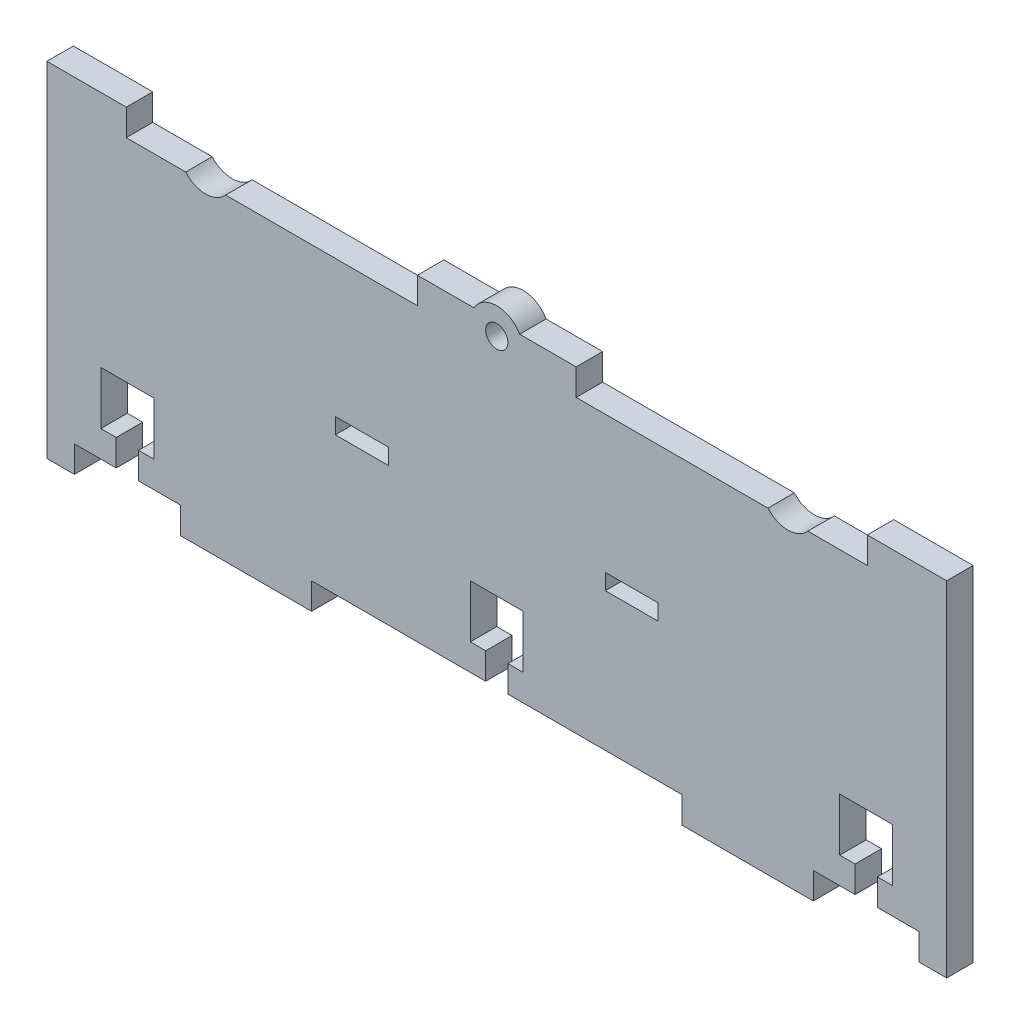
from build123d import *

# Parameters (mm, degrees)
BOSS_EXTRUDE1_DEPTH = 5
SKETCH2_W           = 35
SKETCH2_H           = 65
CUT_EXTRUDE1_DEPTH  = 10
CUT_EXTRUDE2_DEPTH  = 5
SKETCH4_W           = 30
SKETCH4_H           = 5
BOSS_EXTRUDE2_DEPTH = 5
SKETCH5_W           = 20
SKETCH5_H           = 5
CUT_EXTRUDE3_DEPTH  = 5
SKETCH6_R           = 2.1
CUT_EXTRUDE4_DEPTH  = 5
BOSS_EXTRUDE3_DEPTH = 5
SKETCH8_W           = 4.2
SKETCH8_H           = 5
SKETCH8_W_2         = 10
SKETCH8_H_2         = 10
CUT_EXTRUDE5_DEPTH  = 5
SKETCH9_W           = 10
SKETCH9_H           = 3
CUT_EXTRUDE6_DEPTH  = 10


with BuildPart() as part:
    # Sketch1 → Boss-Extrude1 (new body)
    with BuildSketch(Plane.XY):
        Polygon((95, -5), (95, 0), (115, 0), (115, 15), (120, 15), (120, 40), (115, 40), (115, 55), (100, 55), (100, 60), (70, 60), (70, 55), (-70, 55), (-70, 60), (-100, 60), (-100, 55), (-115, 55), (-115, 40), (-120, 40), (-120, 15), (-115, 15), (-115, 0), (-95, 0), (-95, -5), (-35, -5), (-35, 0), (35, 0), (35, -5), align=None)
    extrude(amount=BOSS_EXTRUDE1_DEPTH)

    # Sketch2 → Cut-Extrude1 (cut)
    with BuildSketch(Plane(origin=(0, 0, 0), x_dir=(-1, 0, 0), z_dir=(0, 0, -1))):
        with Locations((102.5, 27.5)):
            Rectangle(SKETCH2_W, SKETCH2_H)
        with Locations((-102.5, 27.5)):
            Rectangle(SKETCH2_W, SKETCH2_H)
    extrude(amount=-CUT_EXTRUDE1_DEPTH, mode=Mode.SUBTRACT)

    # Sketch3 → Cut-Extrude2 (cut)
    with BuildSketch(Plane(origin=(0, 0, 0), x_dir=(-1, 0, 0), z_dir=(0, 0, -1))):
        with BuildLine():
            Line((58.770676698, 55), (51.229323302, 55))
            ThreePointArc((51.229323302, 55), (55, 53.28359517), (58.770676698, 55))
        make_face()
        with BuildLine():
            Line((-58.770676698, 55), (-51.229323302, 55))
            ThreePointArc((-51.229323302, 55), (-55, 53.28359517), (-58.770676698, 55))
        make_face()
    extrude(amount=-CUT_EXTRUDE2_DEPTH, mode=Mode.SUBTRACT)

    # Sketch4 → Boss-Extrude2 (add)
    with BuildSketch(Plane(origin=(0, 55, 0), x_dir=(1, 0, 0), z_dir=(0, 1, 0))):
        with Locations((0, -2.5)):
            Rectangle(SKETCH4_W, SKETCH4_H)
    extrude(amount=BOSS_EXTRUDE2_DEPTH)

    # Sketch5 → Cut-Extrude3 (cut)
    with BuildSketch(Plane(origin=(0, 0, 0), x_dir=(-1, 0, 0), z_dir=(0, 0, -1))):
        with Locations((-69.8, -2.5)):
            Rectangle(SKETCH5_W, SKETCH5_H)
        with Locations((69.8, -2.5)):
            Rectangle(SKETCH5_W, SKETCH5_H)
    extrude(amount=-CUT_EXTRUDE3_DEPTH, mode=Mode.SUBTRACT)

    # Sketch6 → Cut-Extrude4 (cut)
    with BuildSketch(Plane(origin=(0, 0, 0), x_dir=(-1, 0, 0), z_dir=(0, 0, -1))):
        with Locations((0, 57.5)):
            Circle(SKETCH6_R)
    extrude(amount=-CUT_EXTRUDE4_DEPTH, mode=Mode.SUBTRACT)

    # Sketch7 → Boss-Extrude3 (add)
    with BuildSketch(Plane(origin=(0, 0, 0), x_dir=(-1, 0, 0), z_dir=(0, 0, -1))):
        with BuildLine():
            Line((4.330127019, 60), (-4.330127019, 60))
            ThreePointArc((-4.330127019, 60), (0, 62.5), (4.330127019, 60))
        make_face()
    extrude(amount=-BOSS_EXTRUDE3_DEPTH)

    # Sketch8 → Cut-Extrude5 (cut)
    with BuildSketch(Plane(origin=(0, 0, 0), x_dir=(-1, 0, 0), z_dir=(0, 0, -1))):
        with Locations((69.8, 2.5)):
            Rectangle(SKETCH8_W, SKETCH8_H)
        with Locations((69.8, 10)):
            Rectangle(SKETCH8_W_2, SKETCH8_H_2)
        with Locations((-69.8, 10)):
            Rectangle(SKETCH8_W_2, SKETCH8_H_2)
        with Locations((-69.8, 2.5)):
            Rectangle(SKETCH8_W, SKETCH8_H)
        with Locations((0, 2.5)):
            Rectangle(SKETCH8_W, SKETCH8_H)
        with Locations((0, 10)):
            Rectangle(SKETCH8_W_2, SKETCH8_H_2)
    extrude(amount=-CUT_EXTRUDE5_DEPTH, mode=Mode.SUBTRACT)

    # Sketch9 → Cut-Extrude6 (cut)
    with BuildSketch(Plane(origin=(0, 0, 0), x_dir=(-1, 0, 0), z_dir=(0, 0, -1))):
        with Locations((-25.5, 27.625214192)):
            Rectangle(SKETCH9_W, SKETCH9_H)
        with Locations((25.5, 27.625214192)):
            Rectangle(SKETCH9_W, SKETCH9_H)
    extrude(amount=-CUT_EXTRUDE6_DEPTH, mode=Mode.SUBTRACT)


solid = part.part
